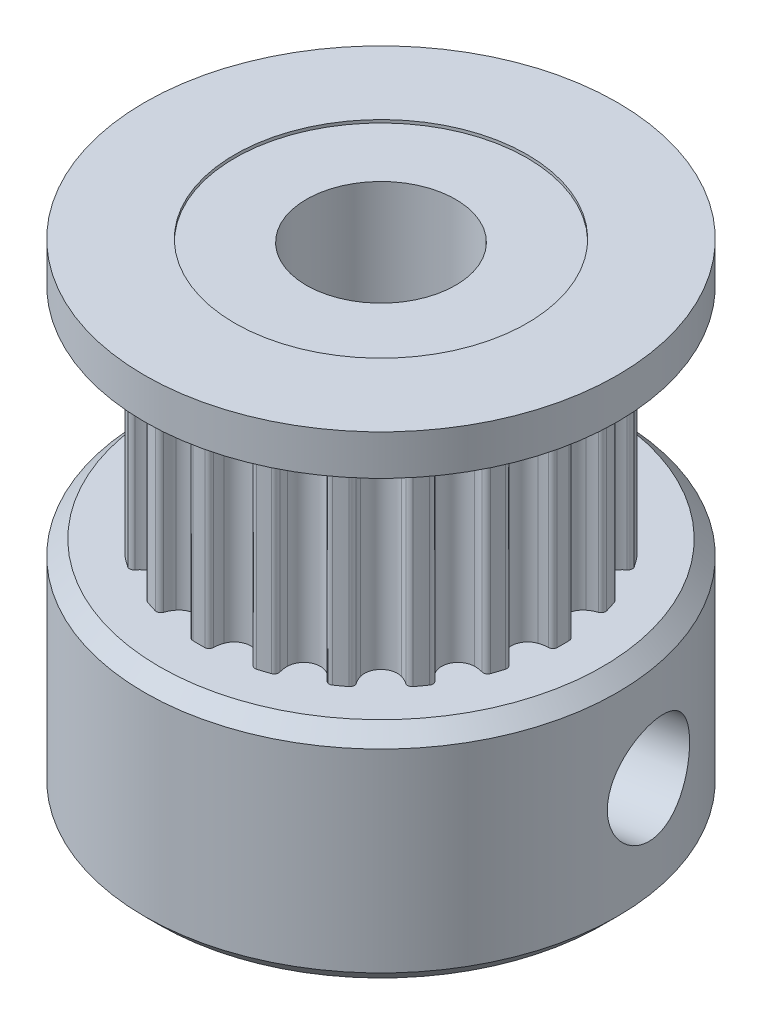
from build123d import *

# Parameters (mm, degrees)
SKETCH1_R               = 6.366197724
BOSS_EXTRUDE1_DEPTH     = 3.68
CUT_EXTRUDE1_DEPTH      = 4.68
CIRPATTERN1_COUNT       = 20
BOSS_EXTRUDE2_START     = 3.68
SKETCH3_R               = 7.925
BOSS_EXTRUDE2_DEPTH     = 1.35
BOSS_EXTRUDE3_START     = -3.68
SKETCH3_2_R             = 7.925
BOSS_EXTRUDE3_DEPTH     = 7.5
SKETCH4_R               = 2.5
CUT_EXTRUDE2_DEPTH      = 6.03
CUT_EXTRUDE2_DEPTH_BACK = 12.18
SKETCH5_R               = 4.9
CUT_EXTRUDE3_DEPTH      = 0.1
CHAMFER1_SIZE           = 0.5
SKETCH6_R               = 1.7
CUT_EXTRUDE4_DEPTH      = 8.925
CIRPATTERN2_COUNT       = 2
CIRPATTERN2_ANGLE       = 80


with BuildPart() as part:
    # Sketch1 → Boss-Extrude1 (new body, symmetric)
    with BuildSketch(Plane(origin=(0, 0, 0), x_dir=(1, 0, 0), z_dir=(0, 1, 0))):
        Circle(SKETCH1_R)
    extrude(amount=BOSS_EXTRUDE1_DEPTH, both=True)

    # Sketch2 → Cut-Extrude1 (cut, symmetric)
    with BuildSketch(Plane(origin=(0, 0, 0), x_dir=(1, 0, 0), z_dir=(0, 1, 0))):
        with BuildLine():
            Line((0, 6.112197724), (0, 6.366197724))
            ThreePointArc((0, 6.366197724), (0.995892735, 6.287819266), (1.967263286, 6.054613829))
            Line((1.967263286, 6.054613829), (1.88877297, 5.813045474))
            ThreePointArc((1.88877297, 5.813045474), (1.792637512, 5.843407547), (1.69601435, 5.872179863))
            ThreePointArc((1.69601435, 5.872179863), (1.58587755, 5.861508268), (1.513024951, 5.778222637))
            ThreePointArc((1.513024951, 5.778222637), (1.451051787, 5.638481511), (1.368503438, 5.509819063))
            ThreePointArc((1.368503438, 5.509819063), (0.838832532, 5.296180172), (0.401103615, 5.663040142))
            ThreePointArc((0.401103615, 5.663040142), (0.362354352, 5.810914245), (0.346596753, 5.962966714))
            ThreePointArc((0.346596753, 5.962966714), (0.30304649, 6.064688748), (0.201597873, 6.10887218))
            ThreePointArc((0.201597873, 6.10887218), (0.10081265, 6.111366281), (0, 6.112197724))
        make_face()
    cut_extrude1 = extrude(amount=CUT_EXTRUDE1_DEPTH, both=True, mode=Mode.SUBTRACT)

    # CirPattern1: Cut-Extrude1 ×20 about axis
    cirpattern1_axis = Axis((0, 0, 0), (0, 1, 0))
    for i in range(1, CIRPATTERN1_COUNT):
        add(cut_extrude1.rotate(cirpattern1_axis, i * 360 / CIRPATTERN1_COUNT), mode=Mode.SUBTRACT)

    # Sketch3 → Boss-Extrude2 (add)
    with BuildSketch(Plane(origin=(0, 0, 0), x_dir=(1, 0, 0), z_dir=(0, 1, 0)).offset(BOSS_EXTRUDE2_START)):
        Circle(SKETCH3_R)
    extrude(amount=BOSS_EXTRUDE2_DEPTH)

    # Sketch3_2 → Boss-Extrude3 (add)
    with BuildSketch(Plane(origin=(0, 0, 0), x_dir=(1, 0, 0), z_dir=(0, 1, 0)).offset(BOSS_EXTRUDE3_START)):
        Circle(SKETCH3_2_R)
    extrude(amount=-BOSS_EXTRUDE3_DEPTH)

    # Sketch4 → Cut-Extrude2 (cut, two sides)
    with BuildSketch(Plane(origin=(0, 0, 0), x_dir=(1, 0, 0), z_dir=(0, 1, 0))) as cut_extrude2_sk:
        Circle(SKETCH4_R)
    extrude(amount=CUT_EXTRUDE2_DEPTH, mode=Mode.SUBTRACT)
    extrude(cut_extrude2_sk.sketch, amount=-CUT_EXTRUDE2_DEPTH_BACK, mode=Mode.SUBTRACT)

    # Sketch5 → Cut-Extrude3 (cut)
    with BuildSketch(Plane(origin=(0, 5.03, 0), x_dir=(1, 0, 0), z_dir=(0, 1, 0))):
        Circle(SKETCH5_R)
    cut_extrude3 = extrude(amount=-CUT_EXTRUDE3_DEPTH, mode=Mode.SUBTRACT)

    # Mirror1: Cut-Extrude3 across plane
    add(cut_extrude3.mirror(Plane.ZX.offset(-3.075)), mode=Mode.SUBTRACT)

    # Chamfer1
    chamfer1_edges = [part.edges().sort_by_distance(p)[0] for p in [
        (-7.925, -3.68, 0),
        (-7.925, -11.18, 0),
    ]]
    chamfer(chamfer1_edges, length=CHAMFER1_SIZE)

    # Sketch6 → Cut-Extrude4 (cut, through all)
    with BuildSketch(Plane.XY):
        with Locations((0, -7.43)):
            Circle(SKETCH6_R)
    cut_extrude4 = extrude(amount=-CUT_EXTRUDE4_DEPTH, mode=Mode.SUBTRACT)

    # CirPattern2: Cut-Extrude4 ×2 about axis
    cirpattern2_axis = Axis((0, -4.18, 0), (0, -1, 0))
    for i in range(1, CIRPATTERN2_COUNT):
        add(cut_extrude4.rotate(cirpattern2_axis, i * CIRPATTERN2_ANGLE / (CIRPATTERN2_COUNT - 1)), mode=Mode.SUBTRACT)


solid = part.part
